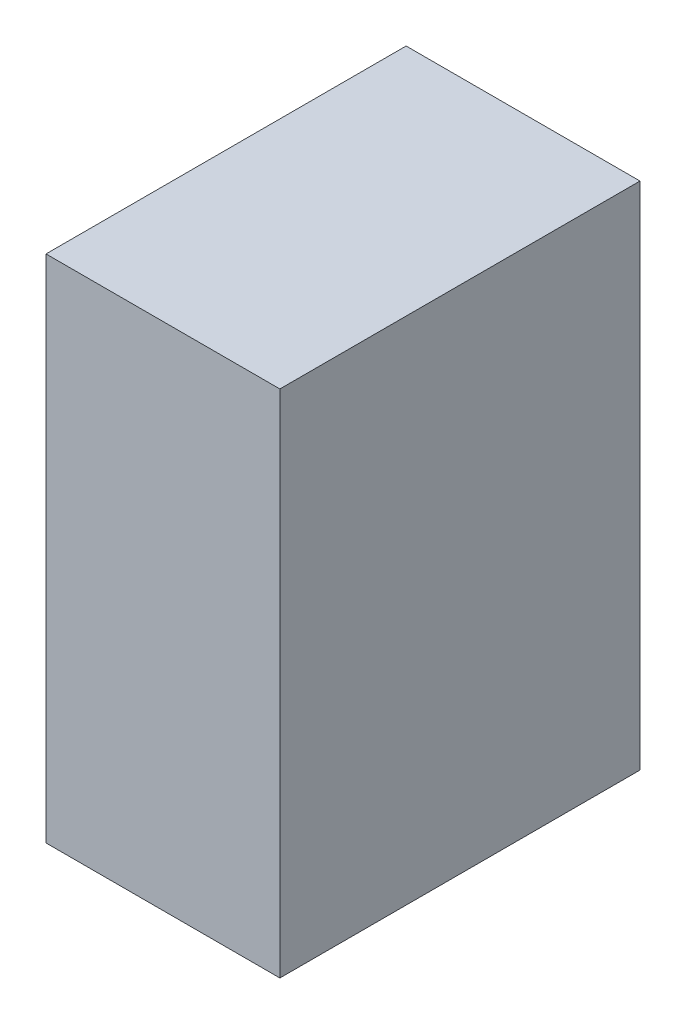
from build123d import *

# Parameters (mm, degrees)
SKETCH1_W           = 68.19
SKETCH1_H           = 105
BOSS_EXTRUDE1_DEPTH = 148.74


with BuildPart() as part:
    # Sketch1 → Boss-Extrude1 (new body)
    with BuildSketch(Plane(origin=(0, 0, 0), x_dir=(1, 0, 0), z_dir=(0, 1, 0))):
        Rectangle(SKETCH1_W, SKETCH1_H)
    extrude(amount=BOSS_EXTRUDE1_DEPTH)


solid = part.part
